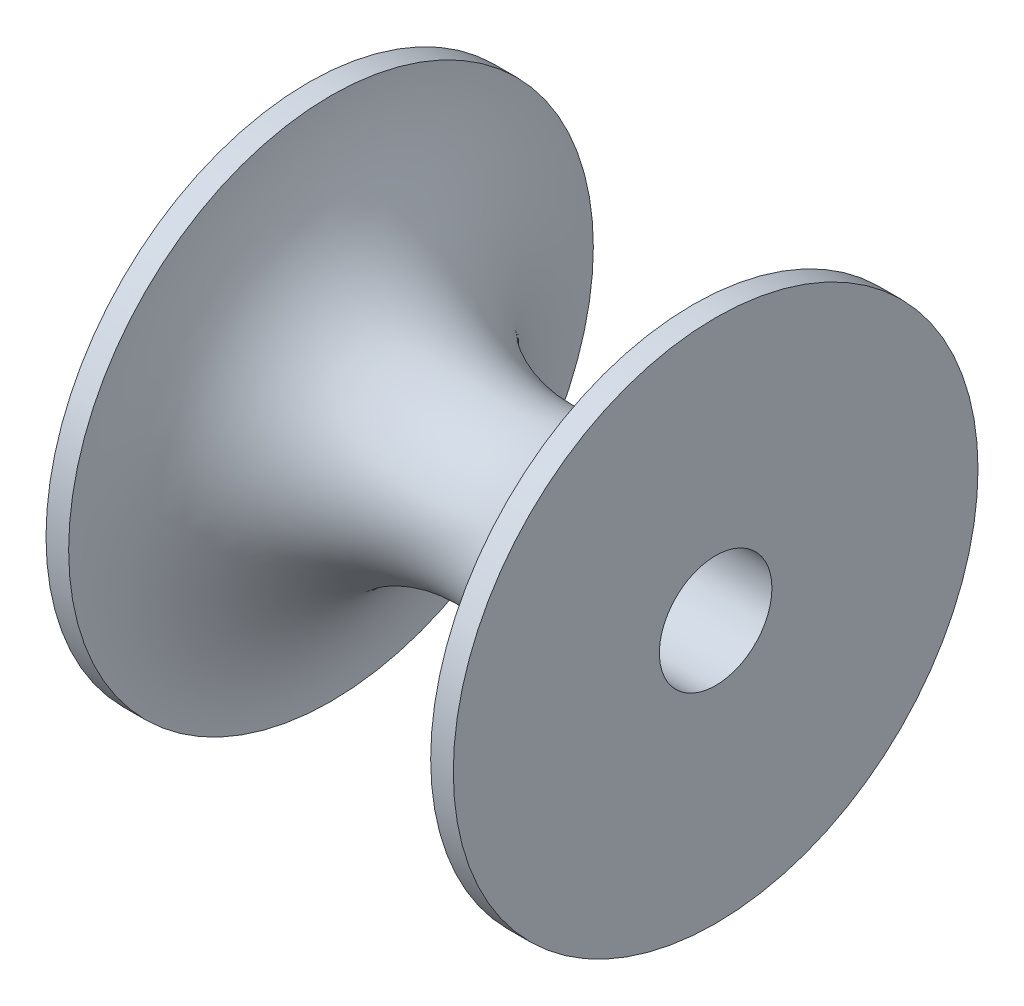
from build123d import *

# Parameters (mm, degrees)
SKETCH2_R          = 4.975
CUT_EXTRUDE1_DEPTH = 36


with BuildPart() as part:
    # Sketch1 → Revolve1 (revolve)
    with BuildSketch(Plane(origin=(0, 0, 0), x_dir=(1, 0, 0), z_dir=(0, 1, 0))):
        with BuildLine():
            Line((-16, 0), (-18, 0))
            Line((-18, 0), (-18, 23.19))
            Line((-18, 23.19), (18, 23.19))
            Line((18, 23.19), (18, 0))
            Line((18, 0), (16, 0))
            ThreePointArc((16, 0), (0, 16), (-16, 0))
        make_face()
    revolve(axis=Axis((-18, 0, -23.19), (1, 0, 0)))

    # Sketch2 → Cut-Extrude1 (cut)
    with BuildSketch(Plane(origin=(18, 0, 0), x_dir=(0, 0, -1), z_dir=(1, 0, 0))):
        with Locations((23.19, 0)):
            Circle(SKETCH2_R)
    extrude(amount=-CUT_EXTRUDE1_DEPTH, mode=Mode.SUBTRACT)


solid = part.part
